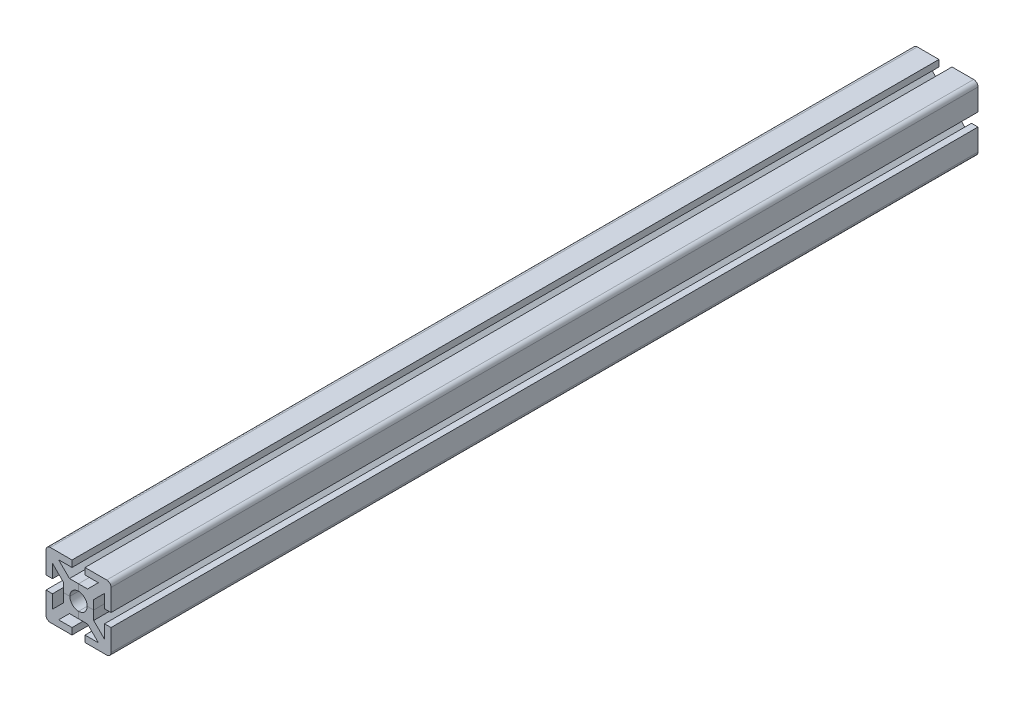
from build123d import *

# Parameters (mm, degrees)
SALIENTE_EXTRUIR1_DEPTH = 200
REDONDEO1_R             = 2
MATRIZC4_COUNT          = 4


with BuildPart() as part:
    # Croquis1 → Saliente-Extruir1 (new body, symmetric)
    with BuildSketch(Plane.XY):
        with BuildLine():
            Line((0, 4), (0, 7))
            Line((0, 7), (4.171572875, 7))
            Line((4.171572875, 7), (9.171572875, 12))
            Line((9.171572875, 12), (3, 12))
            Line((3, 12), (3, 15))
            Line((3, 15), (15, 15))
            Line((15, 15), (2.828427125, 2.828427125))
            ThreePointArc((2.828427125, 2.828427125), (1.530733729, 3.69551813), (0, 4))
        make_face()
    saliente_extruir1 = extrude(amount=SALIENTE_EXTRUIR1_DEPTH, both=True)

    # Simetría1: Saliente-Extruir1 across plane
    add(saliente_extruir1.mirror(Plane(origin=(2.828427125, 2.828427125, 200), x_dir=(0, 0, 1), z_dir=(-0.707106781, 0.707106781, 0))))

    # Redondeo1
    redondeo1_edges = [part.edges().sort_by_distance(p)[0] for p in [
        (15, 15, 0),
    ]]
    fillet(redondeo1_edges, radius=REDONDEO1_R)


with BuildPart() as matrizc4_1:
    # MatrizC4: pattern copy
    add(part.part.rotate(Axis((0, 0, 0), (0, 0, 1)), 1 * 360 / MATRIZC4_COUNT))


with BuildPart() as matrizc4_2:
    # MatrizC4: pattern copy
    add(part.part.rotate(Axis((0, 0, 0), (0, 0, 1)), 2 * 360 / MATRIZC4_COUNT))


with BuildPart() as matrizc4_3:
    # MatrizC4: pattern copy
    add(part.part.rotate(Axis((0, 0, 0), (0, 0, 1)), 3 * 360 / MATRIZC4_COUNT))


solid = Compound([part.part, matrizc4_1.part, matrizc4_2.part, matrizc4_3.part])
